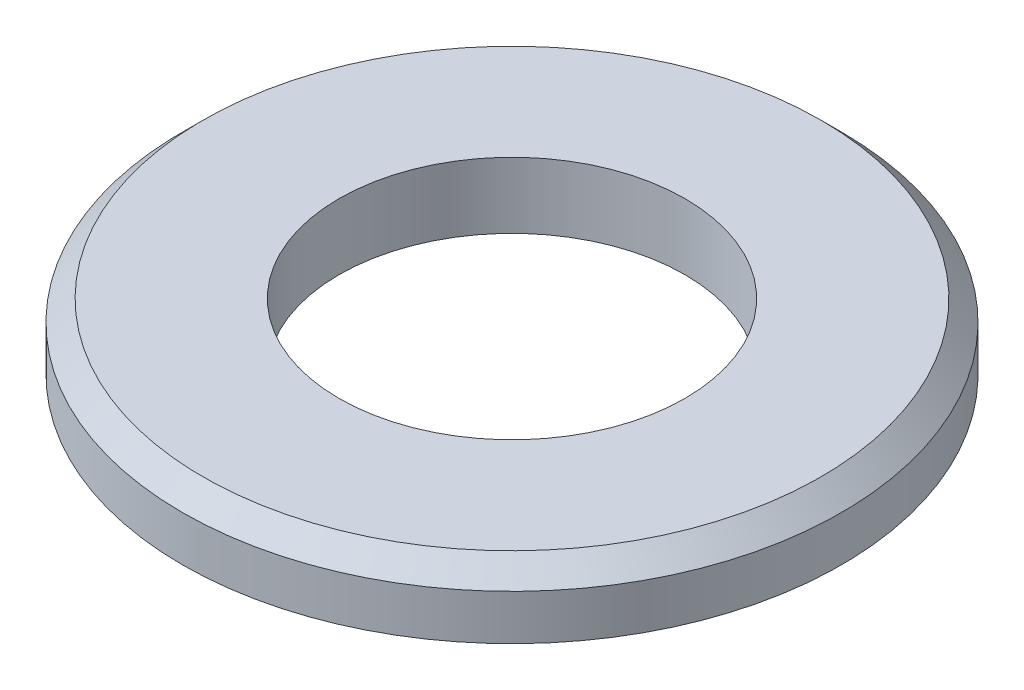
from build123d import *


with BuildPart() as part:
    # Szkic1 → Obrót1 (revolve)
    with BuildSketch(Plane.XY):
        Polygon((4.2, 0), (8, 0), (8, 1.1), (7.5, 1.6), (4.2, 1.6), align=None)
    revolve(axis=Axis((0, 0, 0), (0, 1, 0)))


solid = part.part
